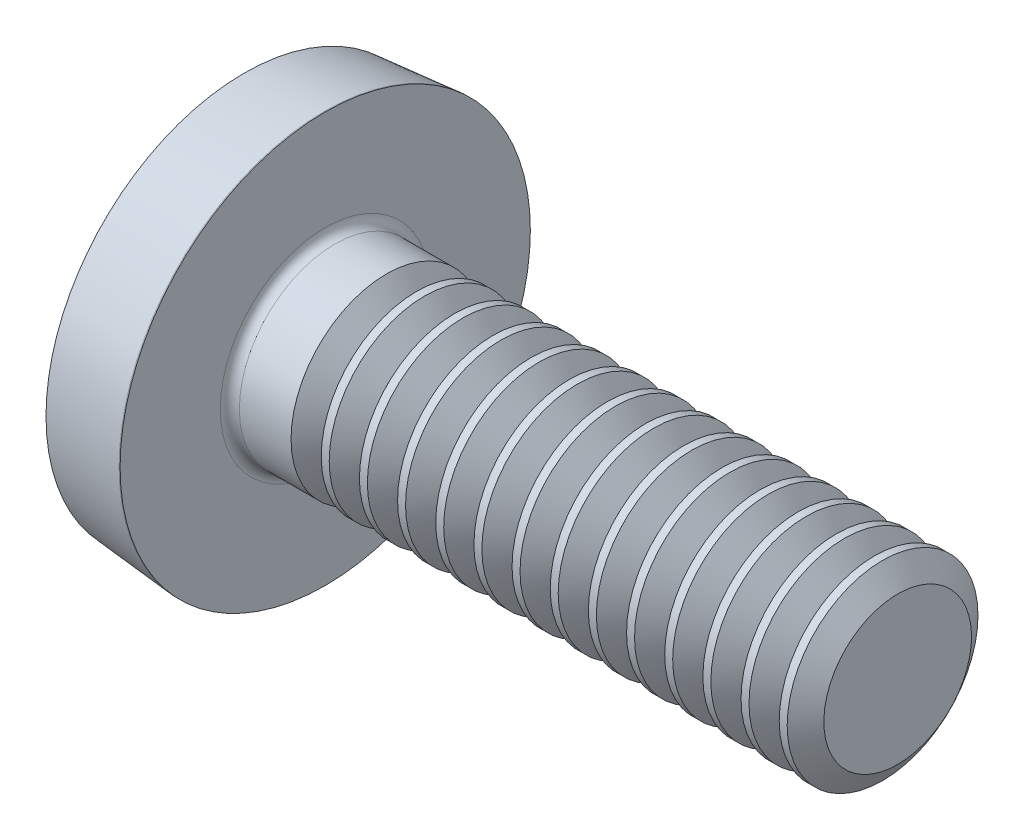
from build123d import *

# Parameters (mm, degrees)
FILLET1_R       = 0.1
SKETCH3_W       = 0.74
SKETCH3_H       = 2.2
SKETCH4_W       = 0.74
SKETCH4_H       = 1.19286532
RECPAT_COUNT    = 2
RECPAT_ANGLE    = 90
THDSCHPAT_COUNT = 14
THDSCHPAT_PITCH = 0.4


with BuildPart() as part:
    # BodySke → Base-Revolve (revolve)
    with BuildSketch(Plane.XY):
        with BuildLine():
            Line((1.2, 1), (1.2, 2.15))
            Line((1.2, 2.15), (1.19, 2.15))
            Line((1.19, 2.15), (0.35, 2.076509523))
            ThreePointArc((0.35, 2.076509523), (0.08811279, 1.052899781), (0, 0))
            Line((0, 0), (7.2, 0))
            Line((7.2, 0), (7.2, 1))
            Line((7.2, 1), (1.2, 1))
        make_face()
    revolve(axis=Axis((-25.4, 0, 0), (1, 0, 0)))

    # Fillet1
    fillet1_edges = [part.edges().sort_by_distance(p)[0] for p in [
        (1.2, -1, 0),
    ]]
    fillet(fillet1_edges, radius=FILLET1_R)

    # Sketch3 → Recess section 0
    with BuildSketch(Plane(origin=(0, 0, 0), x_dir=(0, 0, -1), z_dir=(1, 0, 0))):
        Rectangle(SKETCH3_W, SKETCH3_H)
    # Sketch4 → Recess section 1
    with BuildSketch(Plane(origin=(1.01, 0, 0), x_dir=(0, 0, -1), z_dir=(1, 0, 0))):
        Rectangle(SKETCH4_W, SKETCH4_H)
    recess = loft(mode=Mode.SUBTRACT)

    # RecPat: Recess ×2 about axis
    recpat_axis = Axis((0, 0, 0), (1, 0, 0))
    for i in range(1, RECPAT_COUNT):
        add(recess.rotate(recpat_axis, i * RECPAT_ANGLE / (RECPAT_COUNT - 1)), mode=Mode.SUBTRACT)

    # RecCorSke → RecessCore (revolve, cut)
    with BuildSketch(Plane.XY):
        Polygon((0, 0), (0, 0.62662608), (1.01, 0.556), (1.190655351, 0), align=None)
    revolve(axis=Axis((-3.175, 0, 0), (1, 0, 0)), mode=Mode.SUBTRACT)

    # ThdSchSke → ThreadSchematic (revolve, cut)
    with BuildSketch(Plane.XY):
        Polygon((2, -0.774), (1.841753096, -1), (1.841753096, -1.25), (2.158246904, -1.25), (2.158246904, -1), align=None)
    threadschematic = revolve(axis=Axis((-3.175, 0, 0), (1, 0, 0)), mode=Mode.SUBTRACT)

    # ThdSchPat: ThreadSchematic ×14
    with Locations(*[(i * THDSCHPAT_PITCH, 0, 0) for i in range(1, THDSCHPAT_COUNT)]):
        add(threadschematic, mode=Mode.SUBTRACT)


solid = part.part
